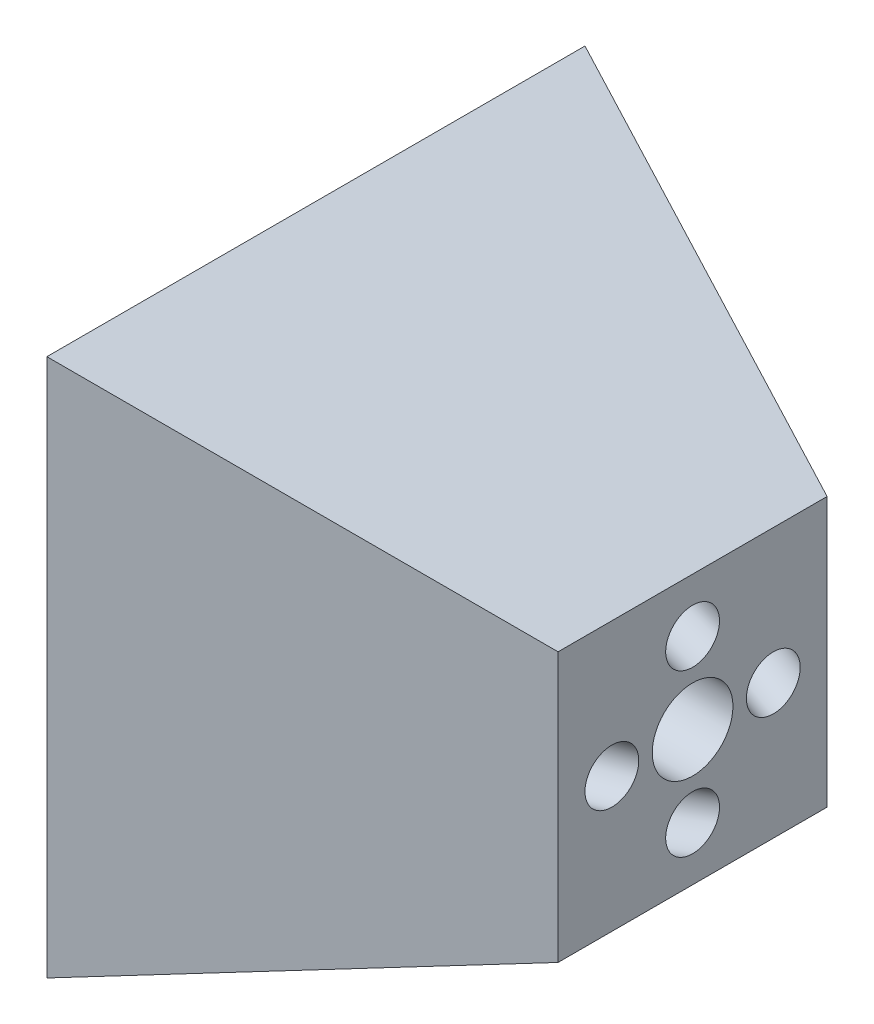
from build123d import *

# Parameters (mm, degrees)
SKETCH1_W          = 50
SKETCH1_H          = 50
SKETCH2_W          = 100
SKETCH2_H          = 100
SKETCH3_R          = 5
SKETCH6_R          = 5
SKETCH7_R          = 7.5
CUT_EXTRUDE1_DEPTH = 71.0000001


with BuildPart() as part:
    # Sketch1 → Loft1 section 0
    with BuildSketch(Plane(origin=(0, 0, 0), x_dir=(0, 0, -1), z_dir=(1, 0, 0))):
        Rectangle(SKETCH1_W, SKETCH1_H)
    # Sketch2 → Loft1 section 1
    with BuildSketch(Plane(origin=(-70, 0, 0), x_dir=(0, 0, -1), z_dir=(1, 0, 0))):
        Rectangle(SKETCH2_W, SKETCH2_H)
    loft()

    # Cut-Sweep2: sweep along a path in Sketch4
    with BuildLine(Plane(origin=(0, 0, 0), x_dir=(1, 0, 0), z_dir=(0, 1, 0))) as cut_sweep2_path:
        Line((0, 15), (-70, 40))
    # Sketch3 → Cut-Sweep2 (sweep, cut)
    with BuildSketch(Plane(origin=(0, 0, 0), x_dir=(0, 0, -1), z_dir=(1, 0, 0))):
        with Locations((15, 0)):
            Circle(SKETCH3_R)
    cut_sweep2 = sweep(path=cut_sweep2_path.line, mode=Mode.SUBTRACT)

    # Cut-Sweep3: sweep along a path in Sketch5
    with BuildLine(Plane.XY) as cut_sweep3_path:
        Line((0, 15), (-70, 40))
    # Sketch6 → Cut-Sweep3 (sweep, cut)
    with BuildSketch(Plane(origin=(0, 0, 0), x_dir=(0, 0, -1), z_dir=(1, 0, 0))):
        with Locations((0, 15)):
            Circle(SKETCH6_R)
    cut_sweep3 = sweep(path=cut_sweep3_path.line, mode=Mode.SUBTRACT)

    # Mirror1: Cut-Sweep2 across plane
    add(cut_sweep2.mirror(Plane.XY), mode=Mode.SUBTRACT)

    # Mirror2: Cut-Sweep3 across plane
    add(cut_sweep3.mirror(Plane.ZX), mode=Mode.SUBTRACT)

    # Sketch7 → Cut-Extrude1 (cut, through all)
    with BuildSketch(Plane(origin=(0, 0, 0), x_dir=(0, 0, -1), z_dir=(1, 0, 0))):
        Circle(SKETCH7_R)
    extrude(amount=-CUT_EXTRUDE1_DEPTH, mode=Mode.SUBTRACT)


solid = part.part
